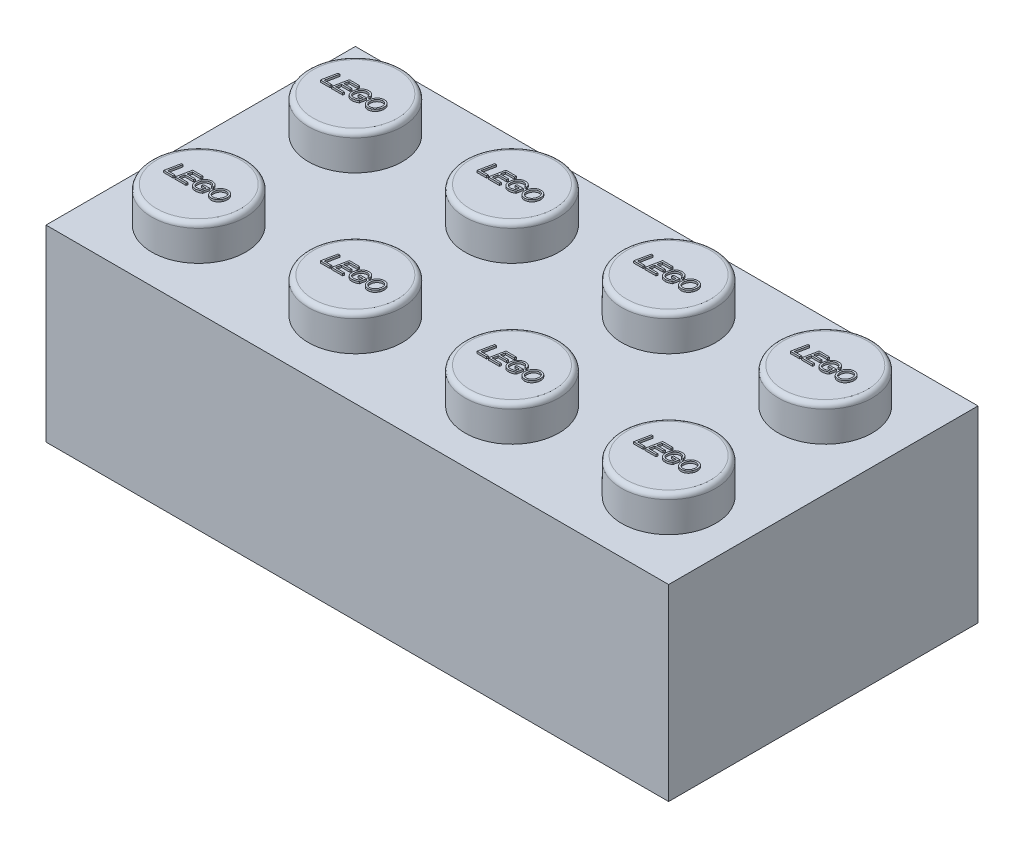
from build123d import *

# Parameters (mm, degrees)
SKETCH1_W            = 31.8
SKETCH1_H            = 15.8
BOSS_EXTRUDE1_DEPTH  = 9.6
SKETCH2_R            = 2.4
BOSS_EXTRUDE2_DEPTH  = 1.8
SHELL1_T             = -1.2
SKETCH3_R            = 3.25
SKETCH3_R_2          = 2.4
BOSS_EXTRUDE3_DEPTH  = 8.4
BOSS_EXTRUDE6_DEPTH  = 0.1
FILLET1_R            = 0.25
LPATTERN1_COUNT      = 4
LPATTERN1_PITCH      = 8
LPATTERN1_COUNT_DIR2 = 2
LPATTERN1_PITCH_DIR2 = 8


with BuildPart() as part:
    # Sketch1 → Boss-Extrude1 (new body)
    with BuildSketch(Plane(origin=(0, 0, 0), x_dir=(1, 0, 0), z_dir=(0, 1, 0))):
        with Locations((15.9, 7.9)):
            Rectangle(SKETCH1_W, SKETCH1_H)
    extrude(amount=BOSS_EXTRUDE1_DEPTH)

    # Sketch2 → Boss-Extrude2 (add)
    with BuildSketch(Plane(origin=(0, 9.6, 0), x_dir=(1, 0, 0), z_dir=(0, 1, 0))):
        with Locations(Location((3.9, 11.9, 0), (0, 0, 90))):  # turned: the seam where the file's is
            Circle(SKETCH2_R)
        with Locations(Location((11.9, 11.9, 0), (0, 0, 90))):  # turned: the seam where the file's is
            Circle(SKETCH2_R)
        with Locations(Location((27.9, 11.9, 0), (0, 0, 90))):  # turned: the seam where the file's is
            Circle(SKETCH2_R)
        with Locations(Location((19.9, 11.9, 0), (0, 0, 90))):  # turned: the seam where the file's is
            Circle(SKETCH2_R)
        with Locations(Location((3.9, 3.9, 0), (0, 0, 90))):  # turned: the seam where the file's is
            Circle(SKETCH2_R)
        with Locations(Location((11.9, 3.9, 0), (0, 0, 90))):  # turned: the seam where the file's is
            Circle(SKETCH2_R)
        with Locations(Location((27.9, 3.9, 0), (0, 0, 90))):  # turned: the seam where the file's is
            Circle(SKETCH2_R)
        with Locations(Location((19.9, 3.9, 0), (0, 0, 90))):  # turned: the seam where the file's is
            Circle(SKETCH2_R)
    extrude(amount=BOSS_EXTRUDE2_DEPTH)

    # Shell1
    shell1_openings = [part.faces().sort_by_distance(p)[0] for p in [
        (15.9, 0, -7.9),
    ]]
    offset(amount=SHELL1_T, openings=shell1_openings, kind=Kind.INTERSECTION)

    # Sketch3 → Boss-Extrude3 (add)
    with BuildSketch(Plane.XZ.offset(-8.4)):
        with Locations(Location((7.9, -7.9, 0), (0, 0, 270))):  # turned: the seam where the file's is
            Circle(SKETCH3_R)
        with Locations(Location((7.9, -7.9, 0), (0, 0, 270))):  # turned: the seam where the file's is
            Circle(SKETCH3_R_2, mode=Mode.SUBTRACT)
        with Locations(Location((15.9, -7.9, 0), (0, 0, 270))):  # turned: the seam where the file's is
            Circle(SKETCH3_R)
        with Locations(Location((15.9, -7.9, 0), (0, 0, 270))):  # turned: the seam where the file's is
            Circle(SKETCH3_R_2, mode=Mode.SUBTRACT)
        with Locations(Location((23.9, -7.9, 0), (0, 0, 270))):  # turned: the seam where the file's is
            Circle(SKETCH3_R)
        with Locations(Location((23.9, -7.9, 0), (0, 0, 270))):  # turned: the seam where the file's is
            Circle(SKETCH3_R_2, mode=Mode.SUBTRACT)
    extrude(amount=BOSS_EXTRUDE3_DEPTH)

    # Sketch5 → Boss-Extrude6 (add)
    with BuildSketch(Plane(origin=(0, 11.4, 0), x_dir=(1, 0, 0), z_dir=(0, 1, 0))):
        Polygon((2.488628794, 11.524872409), (2.642474948, 12.274872409), (2.730365573, 12.274872409), (2.594398025, 11.611410871), (2.988628794, 11.611410871), (2.969398025, 11.524872409), align=None)
        Polygon((3.065551871, 11.524872409), (3.219398025, 12.274872409), (3.748244178, 12.274872409), (3.734572303, 12.188333948), (3.289710525, 12.188333948), (3.242234563, 11.957564717), (3.671321101, 11.957564717), (3.652090332, 11.871026255), (3.224656438, 11.871026255), (3.171321101, 11.611410871), (3.645029034, 11.611410871), (3.627450909, 11.524872409), align=None)
        with BuildLine():
            Line((4.123093938, 11.822949332), (4.141423265, 11.909487794))
            Line((4.141423265, 11.909487794), (4.465642015, 11.909487794))
            Line((4.465642015, 11.909487794), (4.403592736, 11.606753419))
            add(Edge.make_bspline(
                [(4.403592736, 11.606753419), (4.393216975, 11.600187499), (4.372199387, 11.586887289), (4.338479887, 11.569547368), (4.302751522, 11.55394319), (4.265336057, 11.540379417), (4.227028279, 11.529237267), (4.1885473, 11.521317409), (4.150321999, 11.516250619), (4.124912072, 11.515587012), (4.11227663, 11.515257025)],
                knots=[0, 0, 0, 0, 0.952100779, 1.928616355, 2.937626071, 3.97482514, 5.013790607, 6.029397299, 7.020090253, 8, 8, 8, 8], degree=3))
            add(Edge.make_bspline(
                [(4.11227663, 11.515257025), (4.099290189, 11.515509523), (4.07412935, 11.51599873), (4.037667123, 11.520793549), (4.003722844, 11.528351682), (3.972215809, 11.538983557), (3.943304739, 11.552875073), (3.916984644, 11.569838357), (3.892983797, 11.589701849), (3.879448229, 11.605347765), (3.872643217, 11.613213755)],
                knots=[0, 0, 0, 0, 1.162231544, 2.251788547, 3.286290562, 4.271810624, 5.222437566, 6.150319582, 7.070072483, 8, 8, 8, 8], degree=3))
            add(Edge.make_bspline(
                [(3.872643217, 11.613213755), (3.867274071, 11.620215888), (3.856490134, 11.634279684), (3.843168289, 11.657472085), (3.831398375, 11.681838951), (3.822204596, 11.707885928), (3.814740044, 11.735228889), (3.809772199, 11.764162435), (3.806498474, 11.794478371), (3.80612622, 11.815228012), (3.805936486, 11.8258039)],
                knots=[0, 0, 0, 0, 0.931025344, 1.869965919, 2.818748224, 3.78585849, 4.78284169, 5.809032914, 6.883285607, 8, 8, 8, 8], degree=3))
            add(Edge.make_bspline(
                [(3.805936486, 11.8258039), (3.806111535, 11.836826544), (3.806458981, 11.858704896), (3.809178145, 11.891126843), (3.813873767, 11.922824546), (3.820345274, 11.953714043), (3.828407682, 11.983916224), (3.838534704, 12.013319013), (3.850565877, 12.041932552), (3.864184858, 12.069692535), (3.879287102, 12.09607337), (3.895357922, 12.120923064), (3.912333615, 12.14402591), (3.930403164, 12.165218067), (3.94935596, 12.184724764), (3.969383228, 12.202310172), (3.990306463, 12.218155776), (4.012188844, 12.232165064), (4.034867038, 12.24444437), (4.05819703, 12.255165786), (4.082175797, 12.26414353), (4.106665779, 12.27175391), (4.131894308, 12.277451747), (4.157704565, 12.28140182), (4.184132428, 12.284156408), (4.201962948, 12.284376457), (4.210984563, 12.284487794)],
                knots=[0, 0, 0, 0, 1.160897272, 2.304212957, 3.423934589, 4.53397293, 5.626719052, 6.714335181, 7.806635619, 8.894149414, 9.969105247, 11.006440655, 12.009743243, 12.986387491, 13.937572267, 14.87194958, 15.79083293, 16.69948517, 17.605853263, 18.505148493, 19.401577227, 20.300918866, 21.204335112, 22.122718703, 23.050161765, 24, 24, 24, 24], degree=3))
            add(Edge.make_bspline(
                [(4.210984563, 12.284487794), (4.223726547, 12.284163513), (4.248678888, 12.283528482), (4.285065934, 12.277904571), (4.319571376, 12.269230381), (4.346557356, 12.258522079), (4.366864738, 12.24851368), (4.381106101, 12.240351637), (4.394602233, 12.231890347), (4.4069168, 12.222421988), (4.41853274, 12.212622742), (4.42905809, 12.201960204), (4.438886437, 12.190932887), (4.450656443, 12.174935378), (4.463851967, 12.152855353), (4.476825606, 12.123076995), (4.487721193, 12.089779387), (4.492668925, 12.066047668), (4.495239371, 12.053718563)],
                knots=[0, 0, 0, 0, 1.513250879, 2.963365096, 4.364895725, 5.733014485, 6.403689369, 7.053988889, 7.68294403, 8.294715877, 8.898240833, 9.487364028, 10.073503997, 10.65195027, 11.845026783, 13.121175183, 14.504392675, 16, 16, 16, 16], degree=3))
            Line((4.495239371, 12.053718563), (4.408700909, 12.044103178))
            add(Edge.make_bspline(
                [(4.408700909, 12.044103178), (4.407226367, 12.050133141), (4.404322172, 12.062009502), (4.398721131, 12.079115118), (4.3916159, 12.094969665), (4.383958738, 12.109946636), (4.374783212, 12.123708818), (4.364682066, 12.136431437), (4.353356568, 12.147996616), (4.341092436, 12.158535348), (4.32768394, 12.16777189), (4.313495452, 12.1760437), (4.298229974, 12.182731665), (4.282103361, 12.188315604), (4.265062344, 12.192648796), (4.247142397, 12.19582473), (4.228298956, 12.197611722), (4.215445379, 12.197835203), (4.208881198, 12.197949332)],
                knots=[0, 0, 0, 0, 1.079432158, 2.126004382, 3.124393446, 4.098322801, 5.047641653, 5.995681208, 6.919529094, 7.858524372, 8.803197526, 9.747348617, 10.710351979, 11.696394722, 12.712443763, 13.764870275, 14.858543763, 16, 16, 16, 16], degree=3))
            add(Edge.make_bspline(
                [(4.208881198, 12.197949332), (4.201963521, 12.197864118), (4.188195273, 12.197694517), (4.16774033, 12.19539717), (4.147522165, 12.192237267), (4.127742568, 12.187306436), (4.108204299, 12.181379341), (4.089165659, 12.173731098), (4.070297424, 12.165111504), (4.052005218, 12.154847217), (4.034326478, 12.143319154), (4.017365972, 12.130519679), (4.001455658, 12.116228733), (3.986487872, 12.100461021), (3.972452797, 12.083342329), (3.959084561, 12.064982833), (3.947023124, 12.045012371), (3.935593619, 12.02397297), (3.925422482, 12.00185118), (3.916699543, 11.978829347), (3.909182459, 11.955116375), (3.902989345, 11.930645231), (3.898411041, 11.905379902), (3.894882767, 11.879473193), (3.892975131, 11.852725459), (3.89264339, 11.834670766), (3.892474948, 11.825503419)],
                knots=[0, 0, 0, 0, 0.910182469, 1.811535459, 2.706791946, 3.60224261, 4.492655297, 5.392488035, 6.300973671, 7.221790804, 8.150714602, 9.077671133, 10.016091568, 10.962720455, 11.936843414, 12.928565769, 13.949591953, 15.005606631, 16.079396427, 17.151971207, 18.244540305, 19.352633389, 20.472432006, 21.623014359, 22.793075369, 24, 24, 24, 24], degree=3))
            add(Edge.make_bspline(
                [(3.892474948, 11.825503419), (3.892639119, 11.816581975), (3.892959037, 11.799196908), (3.895689015, 11.773973545), (3.900117447, 11.750427762), (3.906473731, 11.72859648), (3.91451346, 11.708403942), (3.924506684, 11.689906041), (3.936289681, 11.673100384), (3.949854767, 11.658008382), (3.965102699, 11.644773874), (3.981768527, 11.633304907), (3.999715515, 11.623473153), (4.019070779, 11.615511262), (4.0398064, 11.60931266), (4.061911595, 11.605095737), (4.085360538, 11.602257396), (4.101450447, 11.601952327), (4.109722544, 11.601795486)],
                knots=[0, 0, 0, 0, 1.204869754, 2.347909566, 3.422600963, 4.43736431, 5.414726527, 6.353100702, 7.270886692, 8.18103633, 9.087280539, 9.991780778, 10.909092918, 11.846320248, 12.813751626, 13.827386831, 14.883022553, 16, 16, 16, 16], degree=3))
            add(Edge.make_bspline(
                [(4.109722544, 11.601795486), (4.11824291, 11.602028501), (4.135478751, 11.602499867), (4.161604919, 11.605415734), (4.188192395, 11.61043456), (4.215238571, 11.617364636), (4.242747041, 11.62627386), (4.270631746, 11.637399064), (4.299253176, 11.649990835), (4.31801569, 11.659966342), (4.327571101, 11.665046688)],
                knots=[0, 0, 0, 0, 0.892369829, 1.805174244, 2.749498628, 3.723900984, 4.727356907, 5.775331026, 6.867016121, 8, 8, 8, 8], degree=3))
            Line((4.327571101, 11.665046688), (4.359872784, 11.822949332))
            Line((4.359872784, 11.822949332), (4.123093938, 11.822949332))
        make_face()
        with BuildLine():
            add(Edge.make_bspline(
                [(4.613628794, 11.839475775), (4.613976246, 11.855665338), (4.61465585, 11.887331504), (4.619937459, 11.933697843), (4.628953074, 11.977674262), (4.641413737, 12.019334322), (4.657350613, 12.05863665), (4.676972222, 12.095503727), (4.700273607, 12.129967956), (4.726895389, 12.161741925), (4.756003509, 12.19044414), (4.786955733, 12.215546485), (4.81935842, 12.236915355), (4.853396372, 12.254268759), (4.888876167, 12.267919582), (4.925964328, 12.277534305), (4.964555569, 12.283357977), (4.990812121, 12.284108081), (5.004103553, 12.284487794)],
                knots=[0, 0, 0, 0, 1.174096974, 2.296488799, 3.379330231, 4.426244142, 5.446159722, 6.450430698, 7.449854931, 8.458171054, 9.452227284, 10.410407653, 11.344354962, 12.262227522, 13.176318736, 14.096137107, 15.036238091, 16, 16, 16, 16], degree=3))
            add(Edge.make_bspline(
                [(5.004103553, 12.284487794), (5.015337387, 12.284266875), (5.037392908, 12.283833142), (5.069619323, 12.279278629), (5.100295315, 12.272322982), (5.129326703, 12.262379529), (5.156656587, 12.249466216), (5.18258091, 12.234007466), (5.206629914, 12.215292552), (5.229173044, 12.194252131), (5.249389683, 12.170619573), (5.267285801, 12.145041995), (5.282094273, 12.11731343), (5.29460786, 12.087864121), (5.303950321, 12.056334453), (5.310695005, 12.022953862), (5.314822304, 11.987666175), (5.315304813, 11.963485528), (5.315551871, 11.95110438)],
                knots=[0, 0, 0, 0, 1.049121968, 2.059753871, 3.034884073, 3.985011149, 4.92080822, 5.855012523, 6.799463835, 7.762878606, 8.731880671, 9.700317542, 10.6740093, 11.663973223, 12.685522105, 13.740981413, 14.843321233, 16, 16, 16, 16], degree=3))
            add(Edge.make_bspline(
                [(5.315551871, 11.95110438), (5.315380883, 11.942137325), (5.315041381, 11.924332929), (5.313138559, 11.897886574), (5.309609508, 11.871919794), (5.304844246, 11.846433982), (5.298690008, 11.821446968), (5.291087846, 11.796998452), (5.282349933, 11.772963827), (5.275335486, 11.757403886), (5.271831919, 11.749632025)],
                knots=[0, 0, 0, 0, 1.035607528, 2.056234338, 3.059809298, 4.060229902, 5.049099918, 6.029597228, 7.015825556, 8, 8, 8, 8], degree=3))
            add(Edge.make_bspline(
                [(5.271831919, 11.749632025), (5.266211484, 11.738360509), (5.25512557, 11.716128233), (5.235385971, 11.684903912), (5.213620369, 11.655965555), (5.189759746, 11.629649286), (5.164503661, 11.605870963), (5.138250233, 11.584847022), (5.111108426, 11.566480914), (5.091999047, 11.55664153), (5.082529034, 11.551765438)],
                knots=[0, 0, 0, 0, 1.082781469, 2.135710598, 3.172121191, 4.193818158, 5.187255887, 6.152625874, 7.084498912, 8, 8, 8, 8], degree=3))
            add(Edge.make_bspline(
                [(5.082529034, 11.551765438), (5.07625656, 11.548822283), (5.063725238, 11.542942367), (5.044324259, 11.535740235), (5.024768561, 11.529305951), (5.004870832, 11.524262077), (4.984729313, 11.520143268), (4.964255961, 11.51730733), (4.943484575, 11.51563778), (4.929537242, 11.515384434), (4.922523025, 11.515257025)],
                knots=[0, 0, 0, 0, 1.004198862, 2.00621631, 2.998238452, 3.988025709, 4.980605787, 5.977743871, 6.982992327, 8, 8, 8, 8], degree=3))
            add(Edge.make_bspline(
                [(4.922523025, 11.515257025), (4.915205227, 11.515340976), (4.900738295, 11.515506943), (4.879326702, 11.517783243), (4.858388012, 11.521012168), (4.837944506, 11.525654179), (4.818063289, 11.531756652), (4.79855789, 11.538884859), (4.779682915, 11.547732923), (4.761180729, 11.557484485), (4.743730846, 11.568826385), (4.727047555, 11.580966355), (4.711637045, 11.594350447), (4.697229341, 11.60875828), (4.683891871, 11.62411469), (4.67179907, 11.640718558), (4.660704464, 11.658205585), (4.650797682, 11.676700991), (4.642163199, 11.695931635), (4.63450366, 11.715527065), (4.628007992, 11.735435146), (4.622722558, 11.755649198), (4.618682196, 11.776174964), (4.615865189, 11.797048725), (4.61396613, 11.818156718), (4.613741384, 11.832360296), (4.613628794, 11.839475775)],
                knots=[0, 0, 0, 0, 1.049755725, 2.075316381, 3.086802409, 4.089362479, 5.080704198, 6.069985429, 7.066939149, 8.070220338, 9.069089437, 10.050927628, 11.029313503, 11.994944209, 12.973330084, 13.945120114, 14.94012881, 15.943409999, 16.953439418, 17.963826795, 18.961635125, 19.957059078, 20.960674896, 21.96189437, 22.97898283, 24, 24, 24, 24], degree=3))
        make_face()
        with BuildLine():
            add(Edge.make_bspline(
                [(4.700167255, 11.835569525), (4.700506259, 11.82497868), (4.70117253, 11.804163637), (4.706679027, 11.773614184), (4.71527845, 11.744340384), (4.725655127, 11.721179328), (4.735541473, 11.703661282), (4.743907518, 11.691227409), (4.753044125, 11.679481539), (4.763150529, 11.668539576), (4.77399755, 11.658242665), (4.785765792, 11.648767364), (4.798420274, 11.640027061), (4.8163556, 11.629552499), (4.839707666, 11.618373461), (4.868916417, 11.608928695), (4.898790979, 11.602929364), (4.918989553, 11.602174561), (4.929133601, 11.601795486)],
                knots=[0, 0, 0, 0, 1.387406571, 2.726782279, 4.056048615, 5.378488988, 6.042927601, 6.691114297, 7.341159978, 7.991636449, 8.641781568, 9.299996786, 9.970118881, 10.655784777, 12.021274488, 13.354070042, 14.671171421, 16, 16, 16, 16], degree=3))
            add(Edge.make_bspline(
                [(4.929133601, 11.601795486), (4.938924346, 11.602088643), (4.958390946, 11.602671518), (4.987133971, 11.608128687), (5.015245667, 11.616237664), (5.042344984, 11.628186742), (5.068393566, 11.642858222), (5.093211055, 11.660264214), (5.116516027, 11.680330506), (5.138435363, 11.702980854), (5.15857654, 11.728287355), (5.176365995, 11.756556796), (5.192036764, 11.787406823), (5.204989331, 11.820689129), (5.21554519, 11.855044033), (5.223253412, 11.889645973), (5.228163528, 11.923969608), (5.228731725, 11.94683173), (5.229013409, 11.958165678)],
                knots=[0, 0, 0, 0, 0.910950425, 1.811211252, 2.715871294, 3.630848645, 4.562273484, 5.496508445, 6.449109721, 7.422169744, 8.428119038, 9.455497925, 10.527648431, 11.645803853, 12.777419164, 13.871671151, 14.944876224, 16, 16, 16, 16], degree=3))
            add(Edge.make_bspline(
                [(5.229013409, 11.958165678), (5.228814243, 11.96708945), (5.228425919, 11.984488579), (5.225316225, 12.009912134), (5.220491271, 12.033991647), (5.213382148, 12.056628108), (5.204311524, 12.077890875), (5.19319653, 12.097749621), (5.180007704, 12.116203297), (5.165045624, 12.133114857), (5.148529719, 12.148258761), (5.130917833, 12.161461296), (5.112498328, 12.172906903), (5.092988614, 12.182118311), (5.072454621, 12.189141318), (5.051036786, 12.194290596), (5.028679702, 12.197326451), (5.013477737, 12.197739521), (5.005756198, 12.197949332)],
                knots=[0, 0, 0, 0, 1.164624597, 2.270727555, 3.33878975, 4.366469921, 5.36227511, 6.351620953, 7.331263368, 8.317775365, 9.294096208, 10.251228292, 11.187501583, 12.120413432, 13.061149964, 14.015755596, 14.992142106, 16, 16, 16, 16], degree=3))
            add(Edge.make_bspline(
                [(5.005756198, 12.197949332), (4.995820921, 12.197681344), (4.976139091, 12.197150458), (4.947132717, 12.192271914), (4.918953591, 12.184626622), (4.891701356, 12.173754193), (4.865388474, 12.159741015), (4.839877055, 12.142910939), (4.815475612, 12.1226549), (4.792052343, 12.099774641), (4.770503333, 12.074245656), (4.751549915, 12.046393147), (4.735604088, 12.016411672), (4.722669097, 11.984245374), (4.712406326, 11.950068634), (4.70528047, 11.91373958), (4.701049669, 11.8753335), (4.700466449, 11.849052028), (4.700167255, 11.835569525)],
                knots=[0, 0, 0, 0, 0.901874071, 1.786616784, 2.663984163, 3.550129189, 4.445509075, 5.367814688, 6.321319647, 7.321764425, 8.338744905, 9.350666257, 10.376359472, 11.417104596, 12.495092797, 13.612964753, 14.775441077, 16, 16, 16, 16], degree=3))
        make_face(mode=Mode.SUBTRACT)
    boss_extrude6 = extrude(amount=BOSS_EXTRUDE6_DEPTH)

    # Fillet1
    fillet1_edges = [part.edges().sort_by_distance(p)[0] for p in [
        (3.9, 11.4, -9.5),
        (11.9, 11.4, -9.5),
        (27.9, 11.4, -9.5),
        (19.9, 11.4, -9.5),
        (3.9, 11.4, -1.5),
        (11.9, 11.4, -1.5),
        (27.9, 11.4, -1.5),
        (19.9, 11.4, -1.5),
    ]]
    fillet(fillet1_edges, radius=FILLET1_R)

    # LPattern1: Boss-Extrude6 4 × 2
    with Locations(*[(i * LPATTERN1_PITCH, 0, j * LPATTERN1_PITCH_DIR2) for i in range(LPATTERN1_COUNT) for j in range(LPATTERN1_COUNT_DIR2) if (i, j) != (0, 0)]):
        add(boss_extrude6)


solid = part.part
